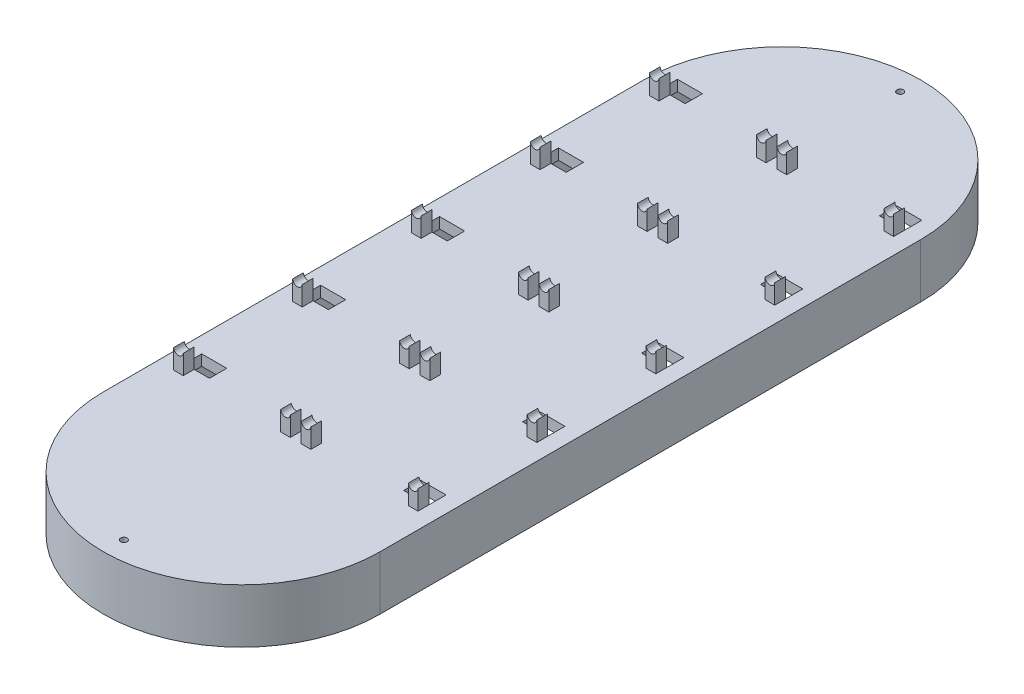
from build123d import *

# Parameters (mm, degrees)
BOSS_EXTRUDE1_DEPTH = 5
SKETCH2_W           = 9
SKETCH2_H           = 5
SKETCH2_W_2         = 18
BOSS_EXTRUDE2_DEPTH = 9
SKETCH3_W           = 1.5
SKETCH3_H           = 9
SKETCH3_W_2         = 3.027864045
SKETCH3_W_3         = 2
SKETCH3_W_4         = 5.05572809
CUT_EXTRUDE1_DEPTH  = 228
BOSS_EXTRUDE3_DEPTH = 20
SKETCH5_W           = 11.583853266
SKETCH5_H           = 8
CUT_EXTRUDE3_DEPTH  = 20
SKETCH6_R           = 1.5
CUT_EXTRUDE5_DEPTH  = 25


with BuildPart() as part:
    # Sketch1 → Boss-Extrude1 (new body)
    with BuildSketch(Plane(origin=(0, 0, 0), x_dir=(1, 0, 0), z_dir=(0, 1, 0))):
        with BuildLine():
            Line((-64, 250), (-64, 0))
            ThreePointArc((-64, 0), (0, -64), (64, 0))
            Line((64, 0), (64, 250))
            ThreePointArc((64, 250), (0, 314), (-64, 250))
        make_face()
    extrude(amount=BOSS_EXTRUDE1_DEPTH)

    # Sketch2 → Boss-Extrude2 (add)
    with BuildSketch(Plane(origin=(0, 5, 0), x_dir=(1, 0, 0), z_dir=(0, 1, 0))):
        with Locations((4.5, 27.5)):
            Rectangle(SKETCH2_W, SKETCH2_H)
        with Locations((-4.5, 27.5)):
            Rectangle(SKETCH2_W, SKETCH2_H)
        with Locations((-53.5, 27.5)):
            Rectangle(SKETCH2_W, SKETCH2_H)
        with Locations((53.5, 27.5)):
            Rectangle(SKETCH2_W, SKETCH2_H)
        with Locations((53.5, 82.5)):
            Rectangle(SKETCH2_W, SKETCH2_H)
        with Locations((4.5, 82.5)):
            Rectangle(SKETCH2_W, SKETCH2_H)
        with Locations((-4.5, 82.5)):
            Rectangle(SKETCH2_W, SKETCH2_H)
        with Locations((-53.5, 82.5)):
            Rectangle(SKETCH2_W, SKETCH2_H)
        with Locations((-53.5, 137.5)):
            Rectangle(SKETCH2_W, SKETCH2_H)
        with Locations((-4.5, 137.5)):
            Rectangle(SKETCH2_W, SKETCH2_H)
        with Locations((4.5, 137.5)):
            Rectangle(SKETCH2_W, SKETCH2_H)
        with Locations((53.5, 137.5)):
            Rectangle(SKETCH2_W, SKETCH2_H)
        with Locations((53.5, 192.5)):
            Rectangle(SKETCH2_W, SKETCH2_H)
        with Locations((-53.5, 192.5)):
            Rectangle(SKETCH2_W, SKETCH2_H)
        with Locations((-53.5, 247.5)):
            Rectangle(SKETCH2_W, SKETCH2_H)
        with Locations((-4.5, 247.5)):
            Rectangle(SKETCH2_W, SKETCH2_H)
        with Locations((4.5, 247.5)):
            Rectangle(SKETCH2_W, SKETCH2_H)
        with Locations((53.5, 247.5)):
            Rectangle(SKETCH2_W, SKETCH2_H)
        with Locations((0, 192.5)):
            Rectangle(SKETCH2_W_2, SKETCH2_H)
    extrude(amount=BOSS_EXTRUDE2_DEPTH)

    # Sketch3 → Cut-Extrude1 (cut)
    with BuildSketch(Plane.XY.offset(-25)):
        with BuildLine():
            ThreePointArc((-56.5, 14), (-54.263932023, 12), (-52.027864045, 14))
            Line((-52.027864045, 14), (-56.5, 14))
        make_face()
        with Locations((-57.25, 9.5)):
            Rectangle(SKETCH3_W, SKETCH3_H)
        with Locations((-50.513932023, 9.5)):
            Rectangle(SKETCH3_W_2, SKETCH3_H)
        with Locations((-8, 9.5)):
            Rectangle(SKETCH3_W_3, SKETCH3_H)
        with BuildLine():
            Line((-2.527864045, 14), (-7, 14))
            ThreePointArc((-7, 14), (-4.763932023, 12), (-2.527864045, 14))
        make_face()
        with Locations((0, 9.5)):
            Rectangle(SKETCH3_W_4, SKETCH3_H)
        with BuildLine():
            Line((7, 14), (2.527864045, 14))
            ThreePointArc((2.527864045, 14), (4.763932023, 12), (7, 14))
        make_face()
        with Locations((8, 9.5)):
            Rectangle(SKETCH3_W_3, SKETCH3_H)
        with Locations((50.513932023, 9.5)):
            Rectangle(SKETCH3_W_2, SKETCH3_H)
        with BuildLine():
            Line((56.5, 14), (52.027864045, 14))
            ThreePointArc((52.027864045, 14), (54.263932023, 12), (56.5, 14))
        make_face()
        with Locations((57.25, 9.5)):
            Rectangle(SKETCH3_W, SKETCH3_H)
    extrude(amount=-CUT_EXTRUDE1_DEPTH, mode=Mode.SUBTRACT)

    # Sketch4 → Boss-Extrude3 (add)
    with BuildSketch(Plane.XZ):
        with BuildLine():
            Line((-64, 0), (-64, -250))
            ThreePointArc((-64, -250), (0, -314), (64, -250))
            Line((64, -250), (64, 0))
            ThreePointArc((64, 0), (0, 64), (-64, 0))
        make_face()
        with BuildLine():
            Line((-59, 0), (-59, -250))
            ThreePointArc((-59, -250), (0, -309), (59, -250))
            Line((59, -250), (59, 0))
            ThreePointArc((59, 0), (0, 59), (-59, 0))
        make_face(mode=Mode.SUBTRACT)
    extrude(amount=BOSS_EXTRUDE3_DEPTH)

    # Sketch5 → Cut-Extrude3 (cut)
    with BuildSketch(Plane(origin=(0, 5, 0), x_dir=(1, 0, 0), z_dir=(0, 1, 0))):
        with Locations((-50.708073367, 254)):
            Rectangle(SKETCH5_W, SKETCH5_H)
        with Locations((-50.708073367, 199)):
            Rectangle(SKETCH5_W, SKETCH5_H)
        with Locations((-50.708073367, 144)):
            Rectangle(SKETCH5_W, SKETCH5_H)
        with Locations((-50.708073367, 89)):
            Rectangle(SKETCH5_W, SKETCH5_H)
        with Locations((-50.708073367, 34)):
            Rectangle(SKETCH5_W, SKETCH5_H)
        with Locations((50.708073367, 144)):
            Rectangle(SKETCH5_W, SKETCH5_H)
        with Locations((50.708073367, 199)):
            Rectangle(SKETCH5_W, SKETCH5_H)
        with Locations((50.708073367, 254)):
            Rectangle(SKETCH5_W, SKETCH5_H)
        with Locations((50.708073367, 89)):
            Rectangle(SKETCH5_W, SKETCH5_H)
        with Locations((50.708073367, 34)):
            Rectangle(SKETCH5_W, SKETCH5_H)
    extrude(amount=-CUT_EXTRUDE3_DEPTH, mode=Mode.SUBTRACT)

    # Sketch6 → Cut-Extrude5 (cut)
    with BuildSketch(Plane.XZ):
        with Locations(Location((0, 54.47166112, 0), (0, 0, 270))):
            Circle(SKETCH6_R)
        with Locations(Location((0, -304.513619398, 0), (0, 0, 270))):
            Circle(SKETCH6_R)
    extrude(amount=-CUT_EXTRUDE5_DEPTH, mode=Mode.SUBTRACT)


solid = part.part
